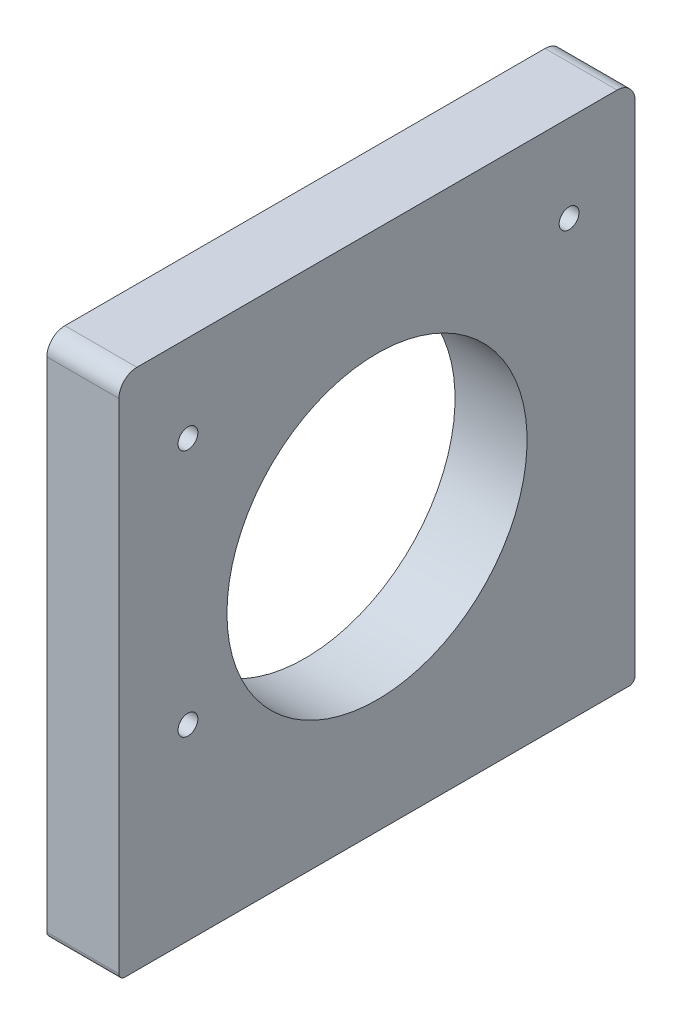
from build123d import *

# Parameters (mm, degrees)
SKETCH1_W           = 40
SKETCH1_H           = 86
BOSS_EXTRUDE1_DEPTH = 12
SKETCH2_W           = 12
SKETCH2_H           = 86
BOSS_EXTRUDE2_DEPTH = 87
SKETCH3_R           = 3
CUT_EXTRUDE1_DEPTH  = 13
SKETCH5_R           = 1.65
CUT_EXTRUDE3_DEPTH  = 13
FILLET1_R           = 3
SKETCH6_R           = 25
CUT_EXTRUDE4_DEPTH  = 13
SKETCH7_W           = 40
SKETCH7_H           = 12
CUT_EXTRUDE5_DEPTH  = 87
SKETCH8_R           = 2.1
CUT_EXTRUDE6_DEPTH  = 12
FILLET2_R           = 1


with BuildPart() as part:
    # Sketch1 → Boss-Extrude1 (new body)
    with BuildSketch(Plane(origin=(0, 0, 0), x_dir=(1, 0, 0), z_dir=(0, 1, 0))):
        with Locations((20, -43)):
            Rectangle(SKETCH1_W, SKETCH1_H)
    extrude(amount=BOSS_EXTRUDE1_DEPTH)

    # Sketch2 → Boss-Extrude2 (add)
    with BuildSketch(Plane(origin=(0, 12, 0), x_dir=(1, 0, 0), z_dir=(0, 1, 0))):
        with Locations((34, -43)):
            Rectangle(SKETCH2_W, SKETCH2_H)
    extrude(amount=BOSS_EXTRUDE2_DEPTH)

    # Sketch3 → Cut-Extrude1 (cut, through all)
    with BuildSketch(Plane(origin=(0, 12, 0), x_dir=(1, 0, 0), z_dir=(0, 1, 0))):
        with Locations((14, -8.4)):
            Circle(SKETCH3_R)
        with Locations((14, -77.6)):
            Circle(SKETCH3_R)
    extrude(amount=-CUT_EXTRUDE1_DEPTH, mode=Mode.SUBTRACT)

    # Sketch5 → Cut-Extrude3 (cut, through all)
    with BuildSketch(Plane.ZY.offset(-28)):
        with Locations((74.5, 84.5)):
            Circle(SKETCH5_R)
        with Locations((74.5, 43.2)):
            Circle(SKETCH5_R)
        with Locations((11, 84.5)):
            Circle(SKETCH5_R)
    extrude(amount=-CUT_EXTRUDE3_DEPTH, mode=Mode.SUBTRACT)

    # Fillet1
    fillet1_edges = [part.edges().sort_by_distance(p)[0] for p in [
        (34, 99, 0),
        (34, 99, 86),
    ]]
    fillet(fillet1_edges, radius=FILLET1_R)

    # Sketch6 → Cut-Extrude4 (cut, through all)
    with BuildSketch(Plane.ZY.offset(-28)):
        with Locations((43, 56)):
            Circle(SKETCH6_R)
    extrude(amount=-CUT_EXTRUDE4_DEPTH, mode=Mode.SUBTRACT)

    # Sketch7 → Cut-Extrude5 (cut, through all)
    with BuildSketch(Plane.XY.offset(86)):
        with Locations((20, 6)):
            Rectangle(SKETCH7_W, SKETCH7_H)
    extrude(amount=-CUT_EXTRUDE5_DEPTH, mode=Mode.SUBTRACT)

    # Sketch8 → Cut-Extrude6 (cut)
    with BuildSketch(Plane.XZ.offset(-12)):
        with Locations((34, 76)):
            Circle(SKETCH8_R)
        with Locations((34, 10)):
            Circle(SKETCH8_R)
    extrude(amount=-CUT_EXTRUDE6_DEPTH, mode=Mode.SUBTRACT)

    # Fillet2
    fillet2_edges = [part.edges().sort_by_distance(p)[0] for p in [
        (34, 12, 0),
        (34, 12, 86),
    ]]
    fillet(fillet2_edges, radius=FILLET2_R)


solid = part.part
